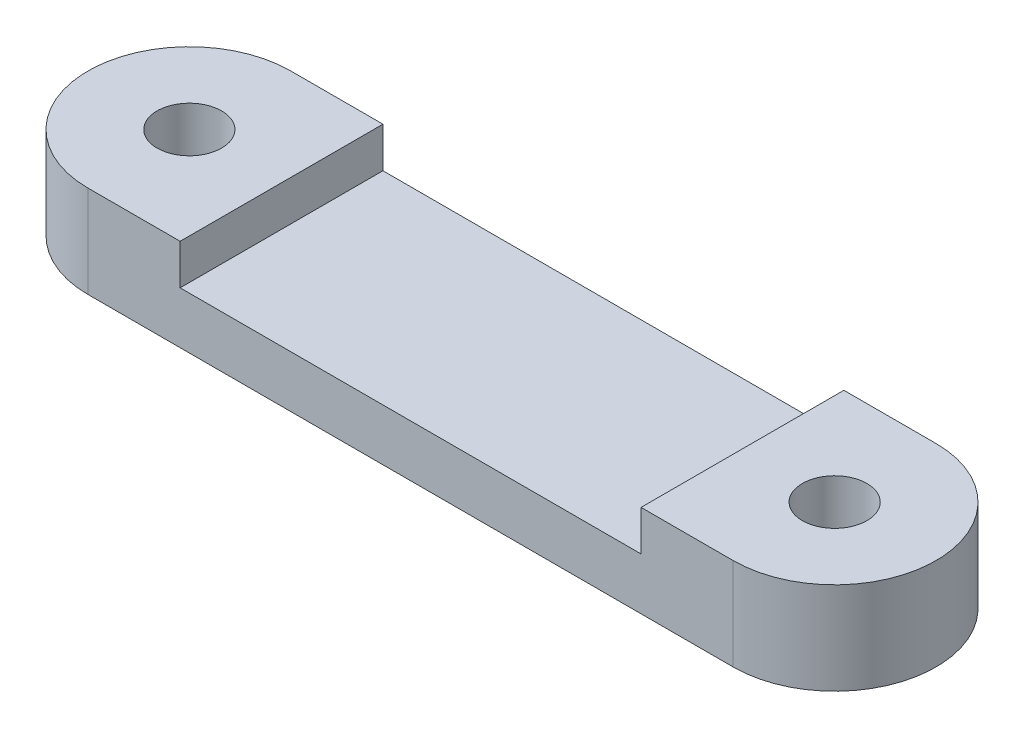
from build123d import *

# Parameters (mm, degrees)
SKETCH1_R           = 1.4
BOSS_EXTRUDE1_DEPTH = 4
SKETCH2_W           = 20
SKETCH2_H           = 8.8
CUT_EXTRUDE1_DEPTH  = 1.75


with BuildPart() as part:
    # Sketch1 → Boss-Extrude1 (new body)
    with BuildSketch(Plane(origin=(0, 0, 0), x_dir=(1, 0, 0), z_dir=(0, 1, 0))):
        with BuildLine():
            Line((0, 0), (28, 0))
            ThreePointArc((28, 0), (32.4, 4.4), (28, 8.8))
            Line((28, 8.8), (0, 8.8))
            ThreePointArc((0, 8.8), (-4.4, 4.4), (0, 0))
        make_face()
        with Locations((0, 4.4)):
            Circle(SKETCH1_R, mode=Mode.SUBTRACT)
        with Locations((28, 4.4)):
            Circle(SKETCH1_R, mode=Mode.SUBTRACT)
    extrude(amount=BOSS_EXTRUDE1_DEPTH)

    # Sketch2 → Cut-Extrude1 (cut)
    with BuildSketch(Plane(origin=(0, 4, 0), x_dir=(1, 0, 0), z_dir=(0, 1, 0))):
        with Locations((14, 4.4)):
            Rectangle(SKETCH2_W, SKETCH2_H)
    extrude(amount=-CUT_EXTRUDE1_DEPTH, mode=Mode.SUBTRACT)


solid = part.part
